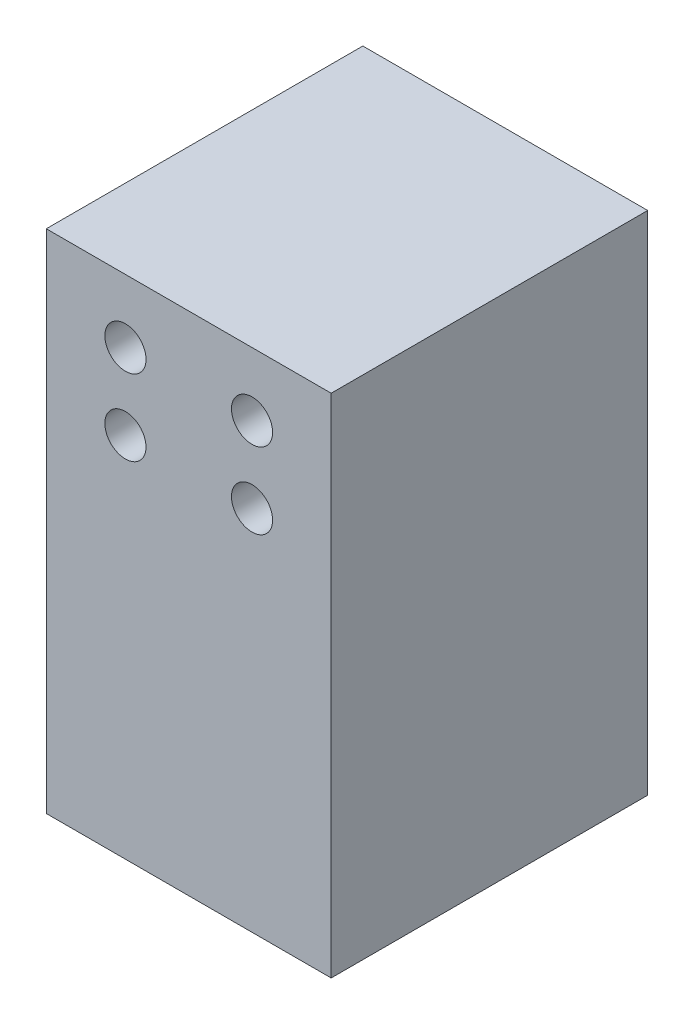
from build123d import *

# Parameters (mm, degrees)
SKETCH1_W           = 45
SKETCH1_H           = 80
BOSS_EXTRUDE1_DEPTH = 25
SKETCH3_R           = 3.25
CUT_EXTRUDE1_DEPTH  = 26
LPATTERN1_COUNT     = 2
LPATTERN1_PITCH     = 12
SKETCH4_R           = 2.25
CUT_EXTRUDE2_DEPTH  = 15


with BuildPart() as part:
    # Sketch1 → Boss-Extrude1 (new body, symmetric)
    with BuildSketch(Plane.XY):
        Rectangle(SKETCH1_W, SKETCH1_H)
    extrude(amount=BOSS_EXTRUDE1_DEPTH, both=True)

    # Sketch3 → Cut-Extrude1 (cut, symmetric)
    with BuildSketch(Plane.XY):
        with Locations((-10, 30)):
            Circle(SKETCH3_R)
        with Locations((10, 30)):
            Circle(SKETCH3_R)
    cut_extrude1 = extrude(amount=CUT_EXTRUDE1_DEPTH, both=True, mode=Mode.SUBTRACT)

    # LPattern1: Cut-Extrude1 ×2
    with Locations(*[(0, -i * LPATTERN1_PITCH, 0) for i in range(1, LPATTERN1_COUNT)]):
        add(cut_extrude1, mode=Mode.SUBTRACT)

    # Sketch4 → Cut-Extrude2 (cut)
    with BuildSketch(Plane.XZ.offset(40)):
        with Locations((-12, 17.5)):
            Circle(SKETCH4_R)
        with Locations((12, 17.5)):
            Circle(SKETCH4_R)
        with Locations((-12, -17.5)):
            Circle(SKETCH4_R)
        with Locations((12, -17.5)):
            Circle(SKETCH4_R)
    extrude(amount=-CUT_EXTRUDE2_DEPTH, mode=Mode.SUBTRACT)


solid = part.part
